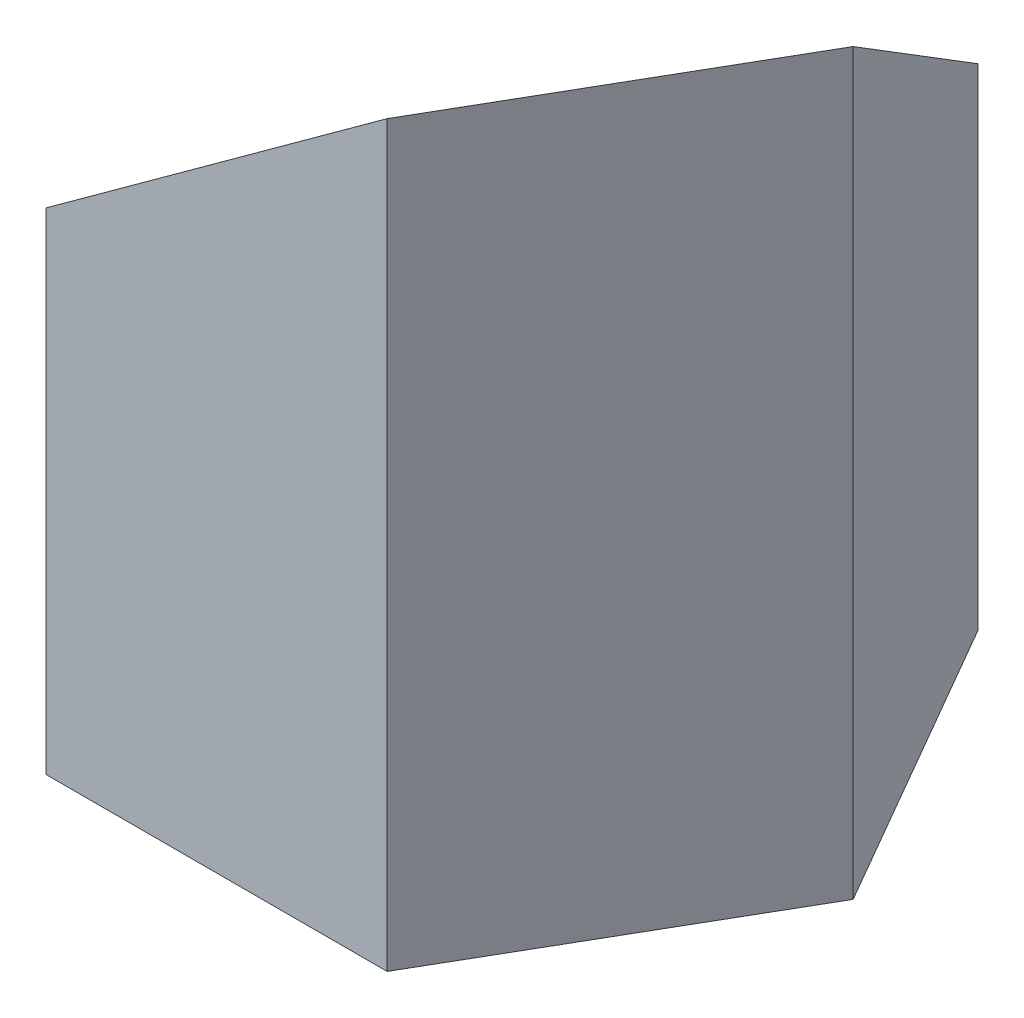
from build123d import *

# Parameters (mm, degrees)
SKETCH1_R           = 12.5
BOSS_EXTRUDE1_DEPTH = 100
DRAFT8_ANGLE        = -40


with BuildPart() as part:
    # Sketch1 → Boss-Extrude1 (new body)
    with BuildSketch(Plane(origin=(0, 0, 0), x_dir=(1, 0, 0), z_dir=(0, 1, 0))):
        Polygon((46.188021535, 0), (23.094010768, 40), (-23.094010768, 40), (-46.188021535, 0), (-23.094010768, -40), (23.094010768, -40), align=None)
        with Locations(Location((0, 0, 0), (0, 0, 270))):
            Circle(SKETCH1_R, mode=Mode.SUBTRACT)
    extrude(amount=BOSS_EXTRUDE1_DEPTH)

    # Draft8
    draft8_faces = [part.faces().sort_by_distance(p)[0] for p in [
        (33.582715627, 100, -19.388989907),
    ]]
    draft(draft8_faces, Plane(origin=(23.094010768, 100, 40), x_dir=(-0.49999999999999944, 0, 0.8660254037844389), z_dir=(0.866025403784439, 0, 0.49999999999999956)), DRAFT8_ANGLE)


solid = part.part
